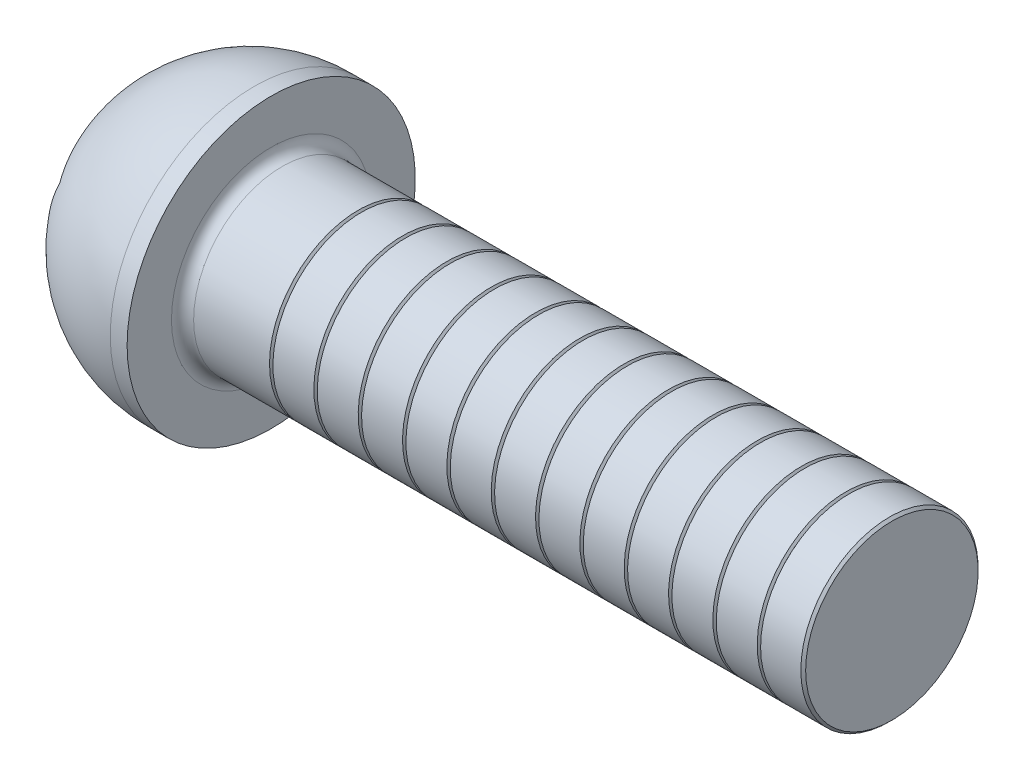
from build123d import *

# Parameters (mm, degrees)
FILLET1_R       = 0.25
HEX_2_DEPTH     = 2.08
THDSCHPAT_COUNT = 13
THDSCHPAT_PITCH = 1


with BuildPart() as part:
    # BodySke → BaseBody (revolve)
    with BuildSketch(Plane.XY):
        with BuildLine():
            Line((17.3, 0), (17.3, 1.9455))
            Line((17.3, 1.9455), (17.2455, 2))
            Line((17.2455, 2), (3.3, 2))
            Line((3.3, 2), (3.3, 3.25))
            Line((3.3, 3.25), (2.92, 3.25))
            ThreePointArc((2.92, 3.25), (1.235280521, 2.841303618), (0, 1.625))
            Line((0, 1.625), (0, 0))
            Line((0, 0), (17.3, 0))
        make_face()
    revolve(axis=Axis((0, 0, 0), (1, 0, 0)))

    # Fillet1
    fillet1_edges = [part.edges().sort_by_distance(p)[0] for p in [
        (3.3, -2, 0),
    ]]
    fillet(fillet1_edges, radius=FILLET1_R)

    # Sketch2 → PreBroach (revolve, cut)
    with BuildSketch(Plane.XY):
        Polygon((0, 2), (2.08, 2), (3.234700538, 0), (0, 0), align=None)
    revolve(axis=Axis((0, 0, 0), (1, 0, 0)), mode=Mode.SUBTRACT)

    # Sketch3 → Hex 2 (cut)
    with BuildSketch(Plane(origin=(0, 0, 0), x_dir=(0, 0, -1), z_dir=(1, 0, 0))):
        Polygon((-2, -1.154700538), (-2, 1.154700538), (0, 2.309401077), (2, 1.154700538), (2, -1.154700538), (0, -2.309401077), align=None)
    extrude(amount=HEX_2_DEPTH, mode=Mode.SUBTRACT)

    # ThdSchSke → ThreadSchematic (revolve, cut)
    with BuildSketch(Plane.XY):
        Polygon((5.3, -1.9455), (5.261838689, -2), (5.261838689, -2.5), (5.338161311, -2.5), (5.338161311, -2), align=None)
    threadschematic = revolve(axis=Axis((-3.175, 0, 0), (1, 0, 0)), mode=Mode.SUBTRACT)

    # ThdSchPat: ThreadSchematic ×13
    with Locations(*[(i * THDSCHPAT_PITCH, 0, 0) for i in range(1, THDSCHPAT_COUNT)]):
        add(threadschematic, mode=Mode.SUBTRACT)


solid = part.part
